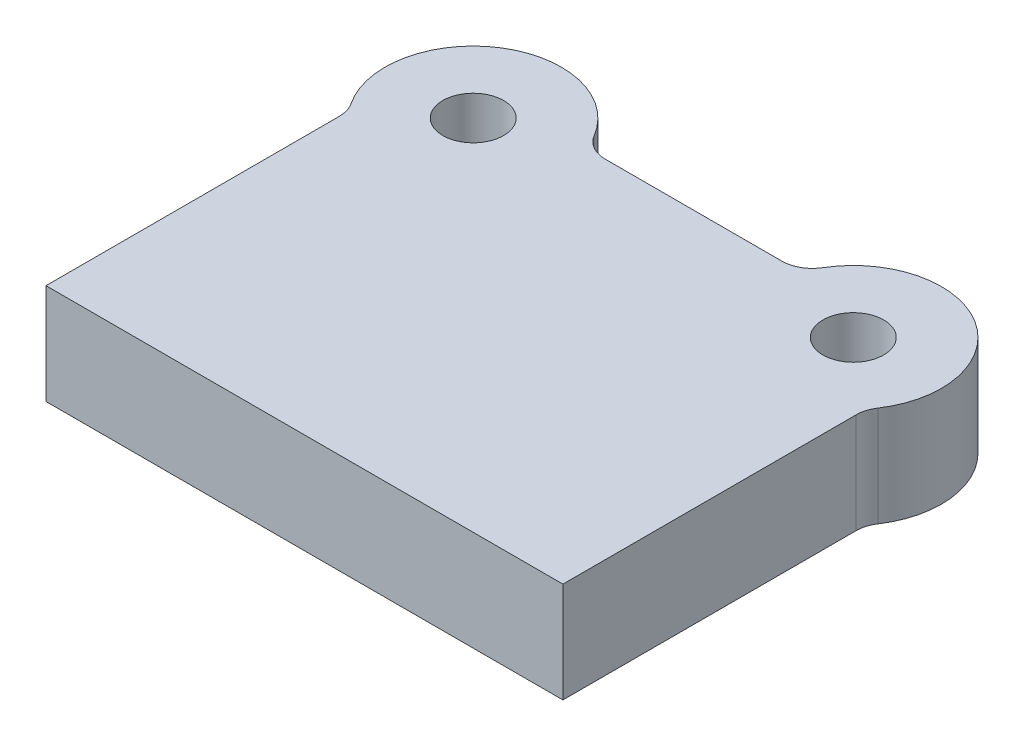
from build123d import *

# Parameters (mm, degrees)
SKETCH1_R           = 10
BOSS_EXTRUDE1_DEPTH = 33
FILLET1_R           = 10


with BuildPart() as part:
    # Sketch1 → Boss-Extrude1 (new body)
    with BuildSketch(Plane(origin=(0, 0, 0), x_dir=(1, 0, 0), z_dir=(0, 1, 0))):
        with BuildLine():
            Line((85, 0), (-85, 0))
            Line((-85, 0), (-85, 99.703825536))
            ThreePointArc((-85, 99.703825536), (-76.843677233, 143.204343345), (-35.278684822, 128))
            Line((-35.278684822, 128), (35.278684822, 128))
            ThreePointArc((35.278684822, 128), (76.843677233, 143.204343345), (85, 99.703825536))
            Line((85, 99.703825536), (85, 0))
        make_face()
        with Locations((-62.5, 118)):
            Circle(SKETCH1_R, mode=Mode.SUBTRACT)
        with Locations((62.5, 118)):
            Circle(SKETCH1_R, mode=Mode.SUBTRACT)
    extrude(amount=BOSS_EXTRUDE1_DEPTH)

    # Fillet1
    fillet1_edges = [part.edges().sort_by_distance(p)[0] for p in [
        (-85, 16.5, -99.703825536),
        (-35.278684822, 16.5, -128),
        (35.278684822, 16.5, -128),
        (85, 16.5, -99.703825536),
    ]]
    fillet(fillet1_edges, radius=FILLET1_R)


solid = part.part
